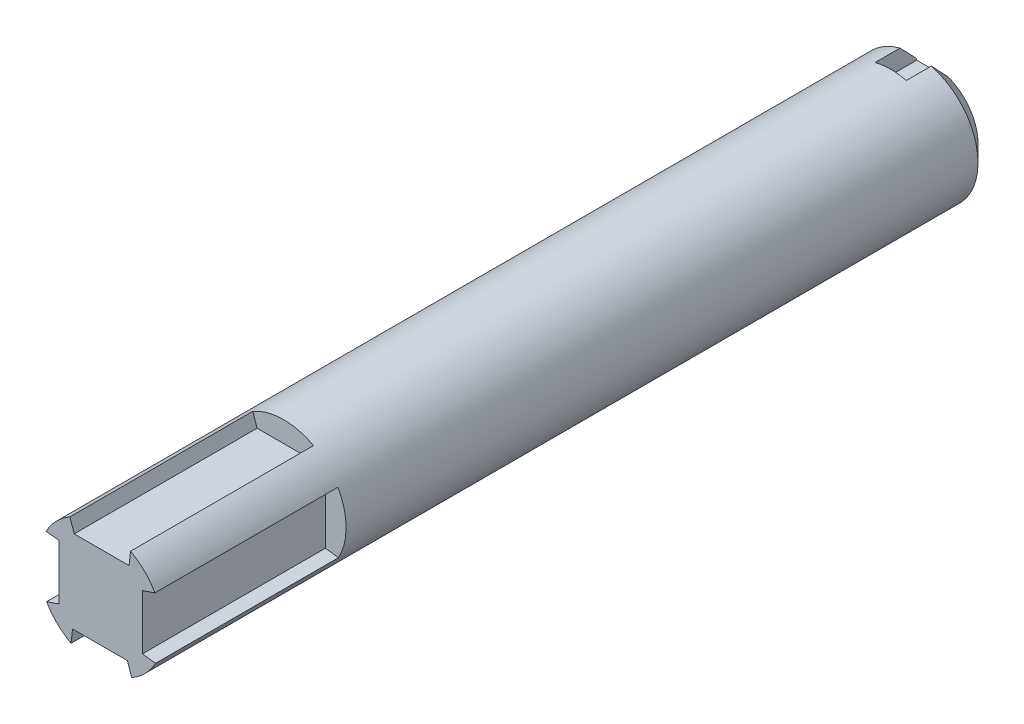
from build123d import *

# Parameters (mm, degrees)
SKETCH1_R           = 9.525
BOSS_EXTRUDE1_DEPTH = 127
SKETCH2_W           = 4.7625
SKETCH2_H           = 3.175
CUT_EXTRUDE1_DEPTH  = 6.35
CHAMFER1_SIZE       = 2.54
CUT_EXTRUDE2_DEPTH  = 27.94


with BuildPart() as part:
    # Sketch1 → Boss-Extrude1 (new body)
    with BuildSketch(Plane.XY):
        Circle(SKETCH1_R)
    extrude(amount=-BOSS_EXTRUDE1_DEPTH)

    # Sketch2 → Cut-Extrude1 (cut)
    with BuildSketch(Plane(origin=(0, 0, -127), x_dir=(-1, 0, 0), z_dir=(0, 0, -1))):
        with Locations((0, 7.9375)):
            Rectangle(SKETCH2_W, SKETCH2_H)
    extrude(amount=-CUT_EXTRUDE1_DEPTH, mode=Mode.SUBTRACT)

    # Chamfer1
    chamfer1_edges = [part.edges().sort_by_distance(p)[0] for p in [
        (-5.83284745, -7.530173678, -127),
    ]]
    chamfer(chamfer1_edges, length=CHAMFER1_SIZE)

    # Sketch3 → Cut-Extrude2 (cut)
    with BuildSketch(Plane.XY):
        with BuildLine():
            Line((-4.720377059, 8.273068682), (-4.064, 6.35))
            Line((-4.064, 6.35), (4.318, 6.35))
            Line((4.318, 6.35), (4.548298042, 8.368907331))
            ThreePointArc((4.548298042, 8.368907331), (-0.098483799, 9.524490849), (-4.720377059, 8.273068682))
        make_face()
        with BuildLine():
            Line((8.273068682, 4.720377059), (6.35, 4.064))
            Line((6.35, 4.064), (6.35, -4.318))
            Line((6.35, -4.318), (8.368907331, -4.548298042))
            ThreePointArc((8.368907331, -4.548298042), (9.524490849, 0.098483799), (8.273068682, 4.720377059))
        make_face()
        with BuildLine():
            Line((4.720377059, -8.273068682), (4.064, -6.35))
            Line((4.064, -6.35), (-4.318, -6.35))
            Line((-4.318, -6.35), (-4.548298042, -8.368907331))
            ThreePointArc((-4.548298042, -8.368907331), (0.098483799, -9.524490849), (4.720377059, -8.273068682))
        make_face()
        with BuildLine():
            Line((-8.273068682, -4.720377059), (-6.35, -4.064))
            Line((-6.35, -4.064), (-6.35, 4.318))
            Line((-6.35, 4.318), (-8.368907331, 4.548298042))
            ThreePointArc((-8.368907331, 4.548298042), (-9.524490849, -0.098483799), (-8.273068682, -4.720377059))
        make_face()
    extrude(amount=-CUT_EXTRUDE2_DEPTH, mode=Mode.SUBTRACT)


solid = part.part
